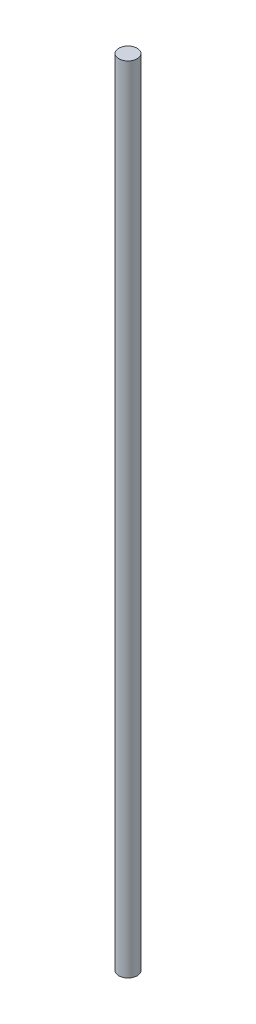
from build123d import *

# Parameters (mm, degrees)
ESQUISSE1_R        = 1.5
BOSS_EXTRU_1_DEPTH = 130


with BuildPart() as part:
    # Esquisse1 → Boss.-Extru.1 (new body)
    with BuildSketch(Plane(origin=(0, 0, 0), x_dir=(1, 0, 0), z_dir=(0, 1, 0))):
        Circle(ESQUISSE1_R)
    extrude(amount=BOSS_EXTRU_1_DEPTH)


solid = part.part
